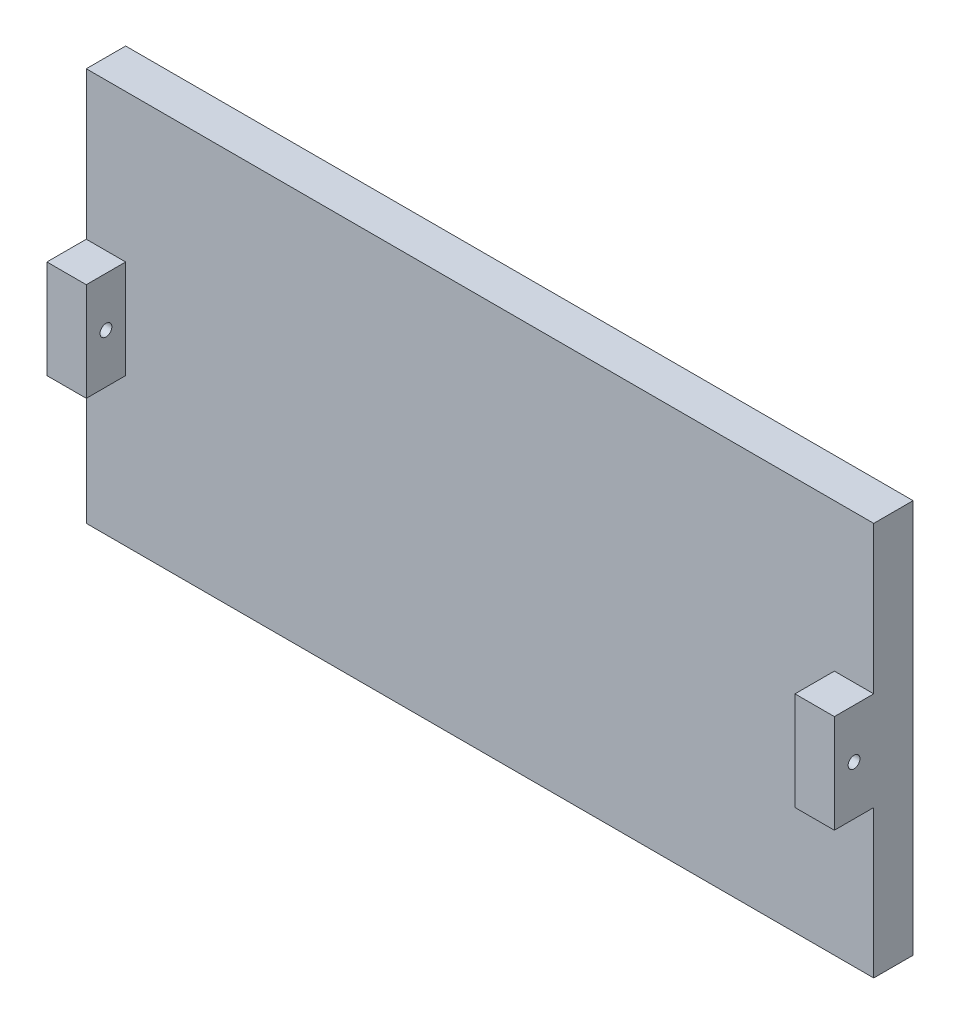
from build123d import *

# Parameters (mm, degrees)
ESQUISSE1_W             = 200
ESQUISSE1_H             = 100
BOSS_EXTRU_1_DEPTH      = 10
ESQUISSE2_W             = 10
ESQUISSE2_H             = 25
BOSS_EXTRU_2_DEPTH      = 10
ESQUISSE3_R             = 1.5
ENL_V_MAT_EXTRU_1_DEPTH = 201


with BuildPart() as part:
    # Esquisse1 → Boss.-Extru.1 (new body)
    with BuildSketch(Plane.XY):
        with Locations((-100, 50)):
            Rectangle(ESQUISSE1_W, ESQUISSE1_H)
    extrude(amount=BOSS_EXTRU_1_DEPTH)

    # Esquisse2 → Boss.-Extru.2 (add)
    with BuildSketch(Plane.XY.offset(10)):
        with Locations((-195, 50)):
            Rectangle(ESQUISSE2_W, ESQUISSE2_H)
        with Locations((-5, 50)):
            Rectangle(ESQUISSE2_W, ESQUISSE2_H)
    extrude(amount=BOSS_EXTRU_2_DEPTH)

    # Esquisse3 → Enlèv. mat.-Extru.1 (cut, through all)
    with BuildSketch(Plane.ZY.offset(200)):
        with Locations((15, 50)):
            Circle(ESQUISSE3_R)
    extrude(amount=-ENL_V_MAT_EXTRU_1_DEPTH, mode=Mode.SUBTRACT)


solid = part.part
